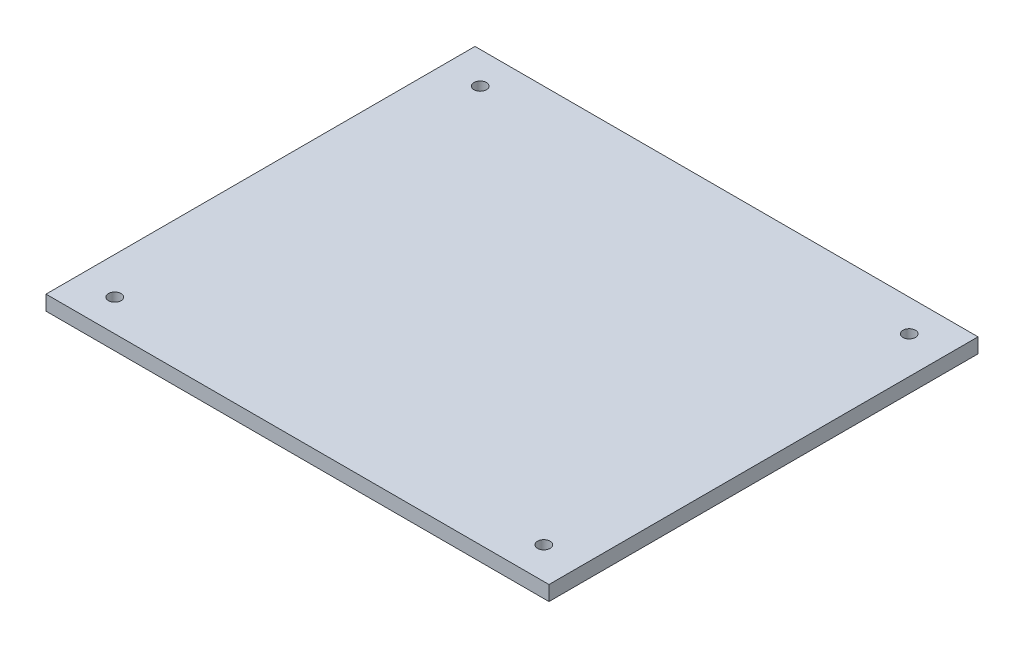
from build123d import *

# Parameters (mm, degrees)
SKETCH1_W           = 172.72
SKETCH1_H           = 147.32
BOSS_EXTRUDE1_DEPTH = 5.08
SKETCH3_R           = 2.159
CUT_EXTRUDE1_DEPTH  = 6.08


with BuildPart() as part:
    # Sketch1 → Boss-Extrude1 (new body)
    with BuildSketch(Plane(origin=(0, 0, 0), x_dir=(1, 0, 0), z_dir=(0, 1, 0))):
        with Locations((86.36, 73.66)):
            Rectangle(SKETCH1_W, SKETCH1_H)
    extrude(amount=BOSS_EXTRUDE1_DEPTH)

    # Sketch3 → Cut-Extrude1 (cut, through all)
    with BuildSketch(Plane(origin=(0, 5.08, 0), x_dir=(1, 0, 0), z_dir=(0, 1, 0))):
        with Locations((12.7, 136.398)):
            Circle(SKETCH3_R)
        with Locations((160.02, 136.398)):
            Circle(SKETCH3_R)
        with Locations((160.02, 10.922)):
            Circle(SKETCH3_R)
        with Locations((12.7, 10.922)):
            Circle(SKETCH3_R)
    extrude(amount=-CUT_EXTRUDE1_DEPTH, mode=Mode.SUBTRACT)


solid = part.part
